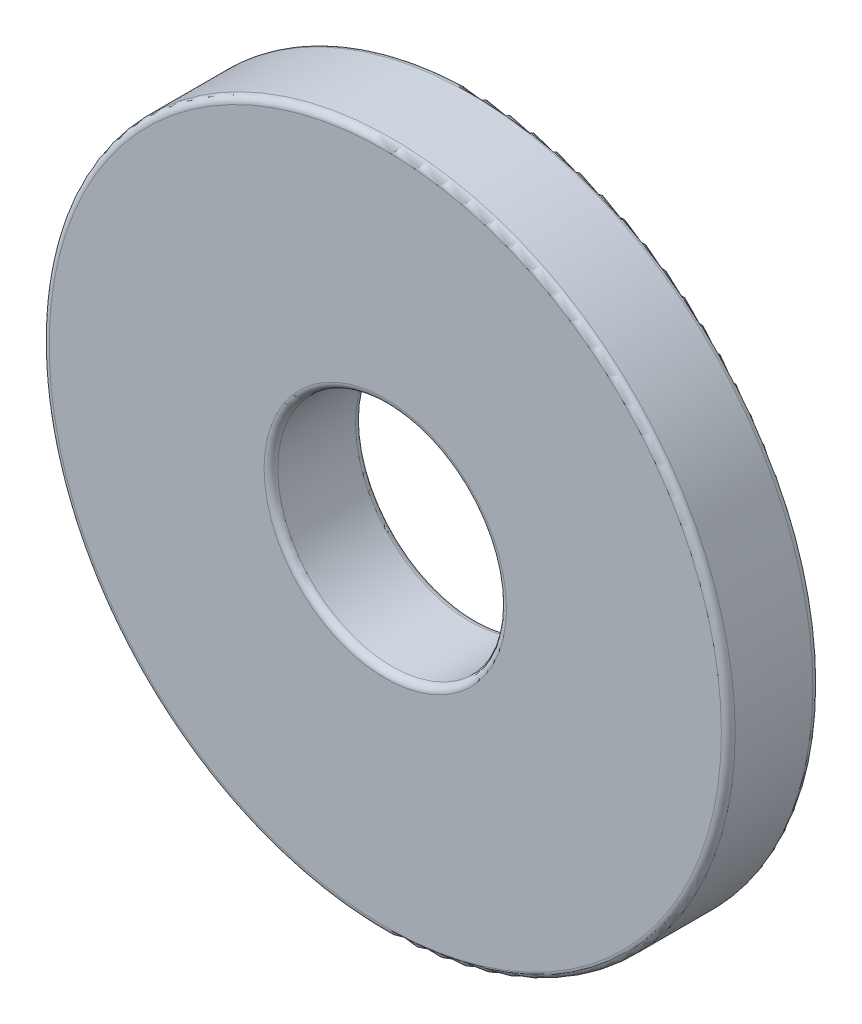
from build123d import *

# Parameters (mm, degrees)
SKETCH1_R           = 7.5
SKETCH1_R_2         = 2.5
BOSS_EXTRUDE1_DEPTH = 2
FILLET1_R           = 0.15


with BuildPart() as part:
    # Sketch1 → Boss-Extrude1 (new body)
    with BuildSketch(Plane.XY):
        Circle(SKETCH1_R)
        Circle(SKETCH1_R_2, mode=Mode.SUBTRACT)
    extrude(amount=BOSS_EXTRUDE1_DEPTH)

    # Fillet1
    fillet1_edges = [part.edges().sort_by_distance(p)[0] for p in [
        (-7.5, 0, 0),
        (-7.5, 0, 2),
        (-2.5, 0, 0),
        (-2.5, 0, 2),
    ]]
    fillet(fillet1_edges, radius=FILLET1_R)


solid = part.part
